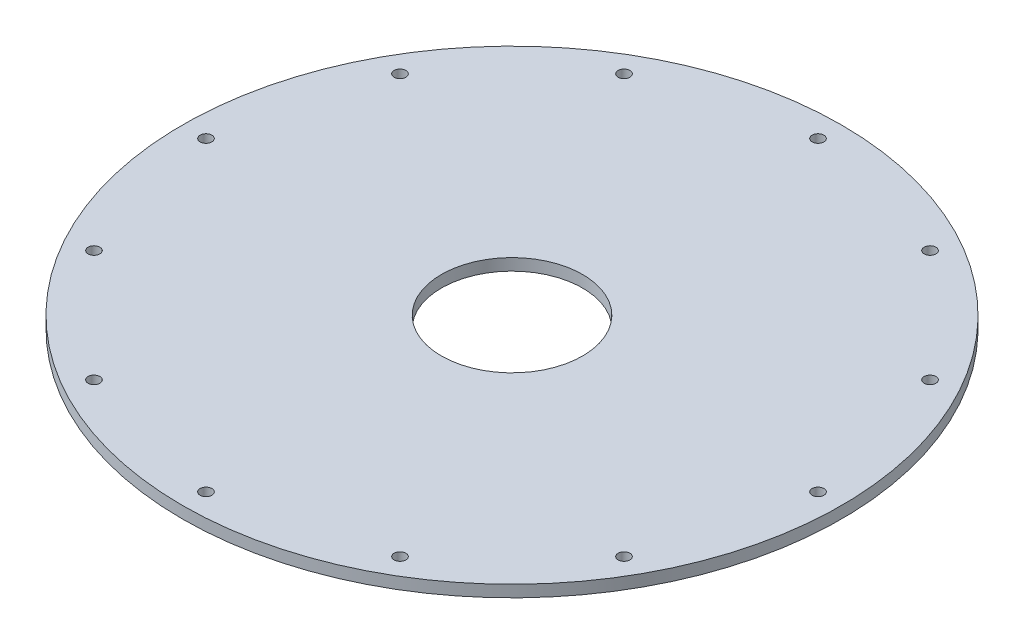
from build123d import *

# Parameters (mm, degrees)
SKETCH1_W                      = 34.925
SKETCH1_H                      = 1.5875
F_1_16_0_0625_DIAMETER_HOLE1_D = 1.5875
CIRPATTERN1_COUNT              = 12


with BuildPart() as part:
    # Sketch1 → Revolve1 (revolve)
    with BuildSketch(Plane.XY):
        with Locations((-26.9875, 0.79375)):
            Rectangle(SKETCH1_W, SKETCH1_H)
    revolve(axis=Axis((0, 55, 0), (0, -1, 0)))

    # 1/16 (0.0625) Diameter Hole1 (through all)
    with Locations(Plane(origin=(0, 1.5875, 0), x_dir=(1, 0, 0), z_dir=(0, 1, 0))):
        with Locations((-41.275, 0)):
            f_1_16_0_0625_diameter_hole1 = Hole(F_1_16_0_0625_DIAMETER_HOLE1_D / 2)

    # CirPattern1: 1/16 (0.0625) Diameter Hole1 ×12 about axis
    cirpattern1_axis = Axis((0, 0, 0), (0, 1, 0))
    for i in range(1, CIRPATTERN1_COUNT):
        add(f_1_16_0_0625_diameter_hole1.rotate(cirpattern1_axis, i * 360 / CIRPATTERN1_COUNT), mode=Mode.SUBTRACT)


solid = part.part
